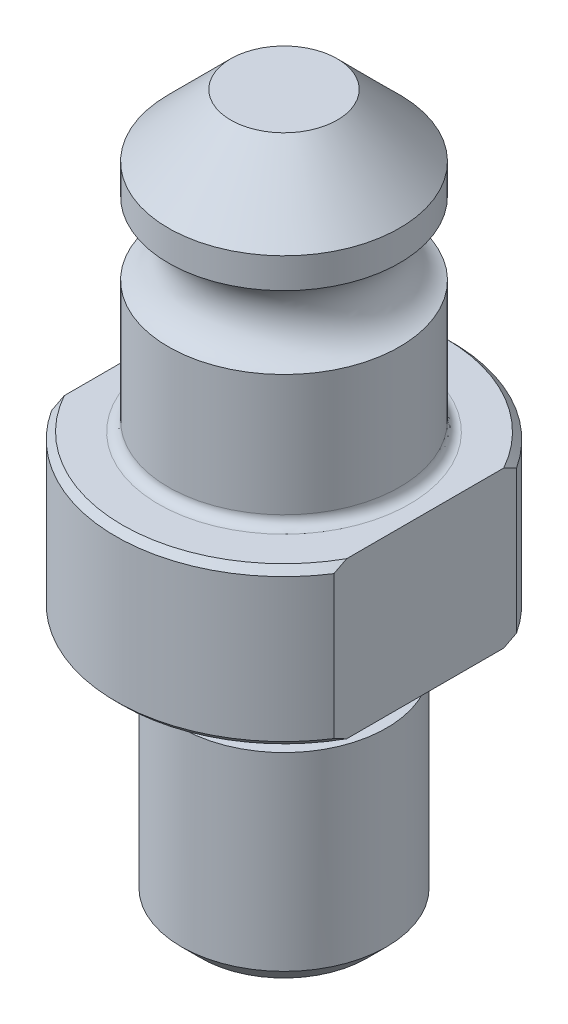
from build123d import *

# Parameters (mm, degrees)
CHAMFER1_SIZE      = 0.508
CHAMFER2_SIZE      = 1.524
CUT_EXTRUDE1_DEPTH = 33.0548
FILLET1_R          = 0.762


with BuildPart() as part:
    # Sketch1 → Revolve1 (revolve)
    with BuildSketch(Plane.XY):
        with BuildLine():
            Line((0, 35.0012), (0, -19.9898))
            Line((0, -19.9898), (-7.9375, -19.9898))
            Line((-7.9375, -19.9898), (-7.9375, -3.81))
            Line((-7.9375, -3.81), (-6.223, -3.81))
            Line((-6.223, -3.81), (-6.223, -1.27))
            ThreePointArc((-6.223, -1.27), (-6.594974388, -0.371974388), (-7.493, 0))
            Line((-7.493, 0), (-13.0048, 0))
            Line((-13.0048, 0), (-13.0048, 12.065))
            Line((-13.0048, 12.065), (-8.9408, 12.065))
            Line((-8.9408, 12.065), (-8.9408, 22.225))
            ThreePointArc((-8.9408, 22.225), (-6.9215, 25.0317), (-8.9408, 27.8384))
            Line((-8.9408, 27.8384), (-8.9408, 30.1752))
            Line((-8.9408, 30.1752), (-4.1148, 35.0012))
            Line((-4.1148, 35.0012), (0, 35.0012))
        make_face()
    revolve(axis=Axis((0, -19.9898, 0), (0, -1, 0)))

    # Chamfer1
    chamfer1_edges = [part.edges().sort_by_distance(p)[0] for p in [
        (13.0048, 12.065, 0),
        (13.0048, 0, 0),
    ]]
    chamfer(chamfer1_edges, length=CHAMFER1_SIZE)

    # Chamfer2
    chamfer2_edges = [part.edges().sort_by_distance(p)[0] for p in [
        (7.9375, -19.9898, 0),
    ]]
    chamfer(chamfer2_edges, length=CHAMFER2_SIZE)

    # Sketch2 → Cut-Extrude1 (cut, through all)
    with BuildSketch(Plane(origin=(0, 12.065, 0), x_dir=(1, 0, 0), z_dir=(0, 1, 0))):
        with BuildLine():
            Line((-10.922, 7.059372425), (-10.922, -7.059372425))
            ThreePointArc((-10.922, -7.059372425), (-13.0048, 0), (-10.922, 7.059372425))
        make_face()
        with BuildLine():
            Line((10.922, 7.059372425), (10.922, -7.059372425))
            ThreePointArc((10.922, -7.059372425), (13.0048, 0), (10.922, 7.059372425))
        make_face()
    extrude(amount=-CUT_EXTRUDE1_DEPTH, mode=Mode.SUBTRACT)

    # Fillet1
    fillet1_edges = [part.edges().sort_by_distance(p)[0] for p in [
        (8.9408, 12.065, 0),
    ]]
    fillet(fillet1_edges, radius=FILLET1_R)


solid = part.part
